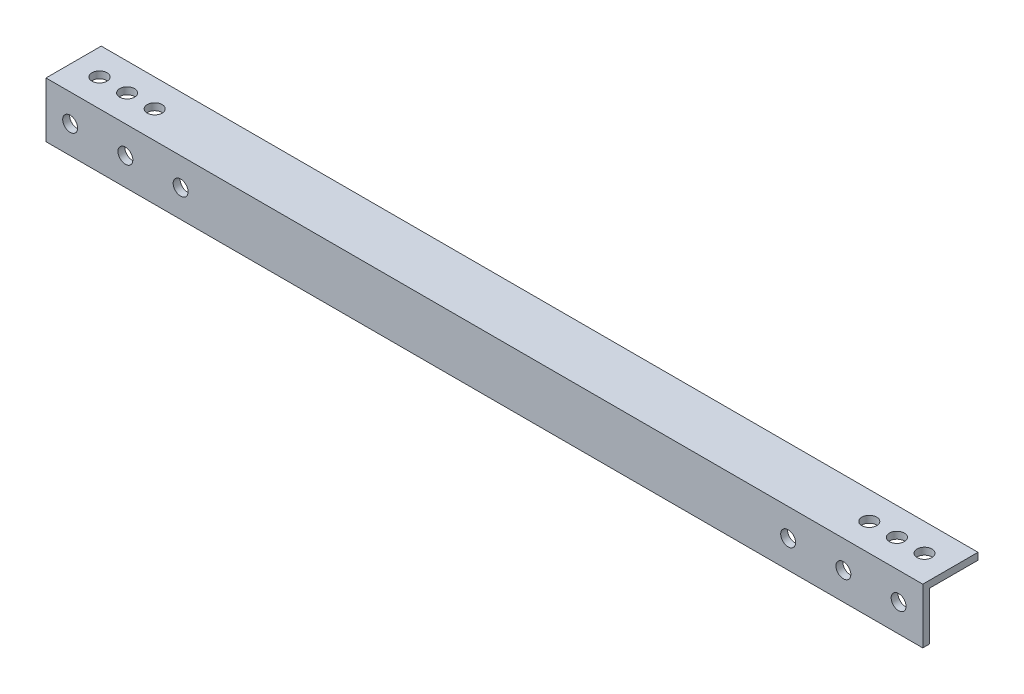
from build123d import *

# Parameters (mm, degrees)
BOSS_EXTRUDE1_DEPTH = 403.225
SKETCH2_R           = 3.429
CUT_EXTRUDE1_DEPTH  = 3.175
SKETCH3_R           = 3.429
CUT_EXTRUDE2_DEPTH  = 3.175


with BuildPart() as part:
    # Sketch1 → Boss-Extrude1 (new body)
    with BuildSketch(Plane(origin=(0, 0, 0), x_dir=(0, 0, -1), z_dir=(1, 0, 0))):
        Polygon((0, 0), (25.4, 0), (25.4, -3.175), (3.175, -3.175), (3.175, -25.4), (0, -25.4), align=None)
    extrude(amount=BOSS_EXTRUDE1_DEPTH)

    # Sketch2 → Cut-Extrude1 (cut)
    with BuildSketch(Plane.XY):
        with Locations((11.1125, -12.7)):
            Circle(SKETCH2_R)
        with Locations((36.5125, -12.7)):
            Circle(SKETCH2_R)
        with Locations((61.9125, -12.7)):
            Circle(SKETCH2_R)
        with Locations((341.3125, -12.7)):
            Circle(SKETCH2_R)
        with Locations((366.7125, -12.7)):
            Circle(SKETCH2_R)
        with Locations((392.1125, -12.7)):
            Circle(SKETCH2_R)
    extrude(amount=-CUT_EXTRUDE1_DEPTH, mode=Mode.SUBTRACT)

    # Sketch3 → Cut-Extrude2 (cut)
    with BuildSketch(Plane(origin=(0, 0, 0), x_dir=(1, 0, 0), z_dir=(0, 1, 0))):
        with Locations((11.8999, 12.7)):
            Circle(SKETCH3_R)
        with Locations((24.5999, 12.7)):
            Circle(SKETCH3_R)
        with Locations((37.2999, 12.7)):
            Circle(SKETCH3_R)
        with Locations((365.9251, 12.7)):
            Circle(SKETCH3_R)
        with Locations((378.6251, 12.7)):
            Circle(SKETCH3_R)
        with Locations((391.3251, 12.7)):
            Circle(SKETCH3_R)
    extrude(amount=-CUT_EXTRUDE2_DEPTH, mode=Mode.SUBTRACT)


solid = part.part
